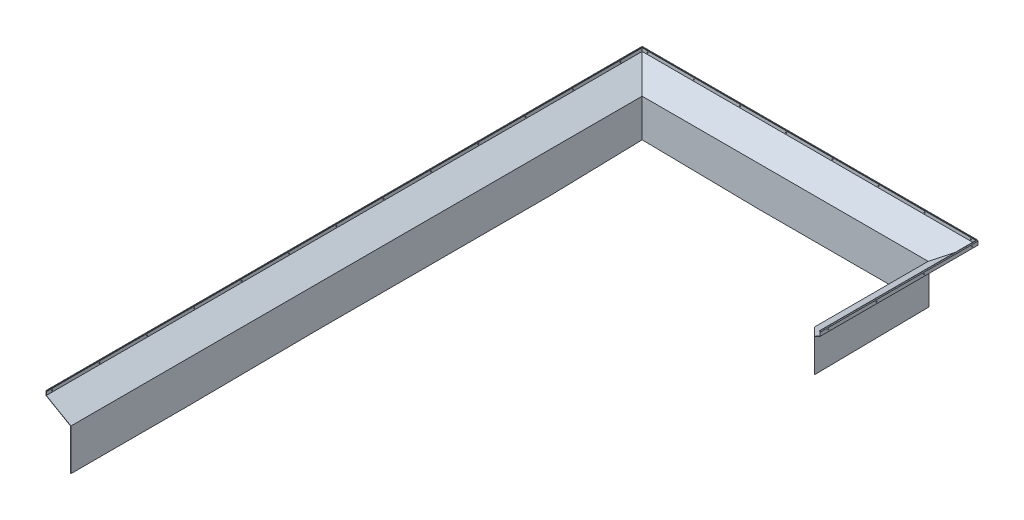
from build123d import *

# Parameters (mm, degrees)
AUFSATZ_LINEAR_AUSTRAGEN1_DEPTH      = 3
AUFSATZ_LINEAR_AUSTRAGEN2_DEPTH      = 3
AUFSATZ_LINEAR_AUSTRAGEN3_DEPTH      = 3
SCHNITT_LINEAR_AUSTRAGEN1_DEPTH      = 521.902814793
SCHNITT_LINEAR_AUSTRAGEN1_DEPTH_BACK = 1
SKIZZE14_R                           = 4.5
SCHNITT_LINEAR_AUSTRAGEN5_DEPTH      = 10
LINEARES_MUSTER1_COUNT               = 13
LINEARES_MUSTER1_PITCH               = 405
SKIZZE15_R                           = 4.5
SCHNITT_LINEAR_AUSTRAGEN6_DEPTH      = 10
LINEARES_MUSTER2_COUNT               = 13
LINEARES_MUSTER2_PITCH               = 395
SKIZZE16_R                           = 4.5
SCHNITT_LINEAR_AUSTRAGEN7_DEPTH      = 10
LINEARES_MUSTER3_COUNT               = 4
LINEARES_MUSTER3_PITCH               = 410


with BuildPart() as part:
    # Austragung1: sweep along a path in Skizze2
    with BuildLine(Plane(origin=(0, 0, 0), x_dir=(1, 0, 0), z_dir=(0, 1, 0))) as austragung1_path:
        Line((0, 0), (0, 5100))
        Line((0, 5100), (2873, 5100))
        Line((2873, 5100), (2873, 3750))
    # Skizze1 → Austragung1 (sweep)
    with BuildSketch(Plane.XY):
        Polygon((0, 511.24355653), (0, 481.24355653), (210, 360), (210, 38.284271247), (213, 38.284271247), (213, 361.732050808), (3, 482.975607337), (3, 510.848599037), (5.48596793, 520.126357657), (2.588190451, 520.902814793), align=None)
    sweep(path=austragung1_path.line, transition=Transition.RIGHT)

    # Skizze4 → Aufsatz-Linear austragen1 (add)
    with BuildSketch(Plane.ZY.offset(-210)):
        Polygon((-4890, 38.284271247), (-4100, 18.284271247), (-2105, 18.284271247), (-1000, 8.284271247), (0, 8.284271247), (0, 38.284271247), align=None)
    extrude(amount=-AUFSATZ_LINEAR_AUSTRAGEN1_DEPTH)

    # Skizze6 → Aufsatz-Linear austragen2 (add)
    with BuildSketch(Plane(origin=(0, 0, -4890), x_dir=(-1, 0, 0), z_dir=(0, 0, -1))):
        Polygon((-210, 38.284271247), (-1210, 23.284271247), (-2663, 23.284271247), (-2663, 38.284271247), align=None)
    extrude(amount=-AUFSATZ_LINEAR_AUSTRAGEN2_DEPTH)

    # Skizze7 → Aufsatz-Linear austragen3 (add)
    with BuildSketch(Plane(origin=(2663, 0, 0), x_dir=(0, 0, -1), z_dir=(1, 0, 0))):
        Polygon((4890, 23.284271247), (3750, 8.284271247), (3750, 38.284271247), (4890, 38.284271247), align=None)
    extrude(amount=-AUFSATZ_LINEAR_AUSTRAGEN3_DEPTH)

    # Skizze8 → Schnitt-Linear austragen1 (cut, two sides)
    with BuildSketch(Plane(origin=(0, 0, 0), x_dir=(1, 0, 0), z_dir=(0, 1, 0))) as schnitt_linear_austragen1_sk:
        Polygon((2823, 3750), (2637.076527488, 3935.923472512), (2637.076527488, 3750), align=None)
    extrude(amount=SCHNITT_LINEAR_AUSTRAGEN1_DEPTH, mode=Mode.SUBTRACT)
    extrude(schnitt_linear_austragen1_sk.sketch, amount=-SCHNITT_LINEAR_AUSTRAGEN1_DEPTH_BACK, mode=Mode.SUBTRACT)

    # Skizze14 → Schnitt-Linear austragen5 (cut)
    with BuildSketch(Plane(origin=(3, 0, 0), x_dir=(0, 0, -1), z_dir=(1, 0, 0))):
        with Locations((50, 496.912103187)):
            Circle(SKIZZE14_R)
    schnitt_linear_austragen5 = extrude(amount=-SCHNITT_LINEAR_AUSTRAGEN5_DEPTH, mode=Mode.SUBTRACT)

    # Lineares Muster1: Schnitt-Linear austragen5 ×13
    with Locations(*[(0, 0, -i * LINEARES_MUSTER1_PITCH) for i in range(1, LINEARES_MUSTER1_COUNT)]):
        add(schnitt_linear_austragen5, mode=Mode.SUBTRACT)

    # Skizze15 → Schnitt-Linear austragen6 (cut)
    with BuildSketch(Plane.XY.offset(-5097)):
        with Locations((50, 496.912103187)):
            Circle(SKIZZE15_R)
    schnitt_linear_austragen6 = extrude(amount=-SCHNITT_LINEAR_AUSTRAGEN6_DEPTH, mode=Mode.SUBTRACT)

    # Lineares Muster2: Schnitt-Linear austragen6 ×13
    with Locations(*[(i * LINEARES_MUSTER2_PITCH, 0, 0) for i in range(1, LINEARES_MUSTER2_COUNT)]):
        add(schnitt_linear_austragen6, mode=Mode.SUBTRACT)

    # Skizze16 → Schnitt-Linear austragen7 (cut)
    with BuildSketch(Plane.ZY.offset(-2870)):
        with Locations((-5050, 496.912103187)):
            Circle(SKIZZE16_R)
    schnitt_linear_austragen7 = extrude(amount=-SCHNITT_LINEAR_AUSTRAGEN7_DEPTH, mode=Mode.SUBTRACT)

    # Lineares Muster3: Schnitt-Linear austragen7 ×4
    with Locations(*[(0, 0, i * LINEARES_MUSTER3_PITCH) for i in range(1, LINEARES_MUSTER3_COUNT)]):
        add(schnitt_linear_austragen7, mode=Mode.SUBTRACT)


solid = part.part
